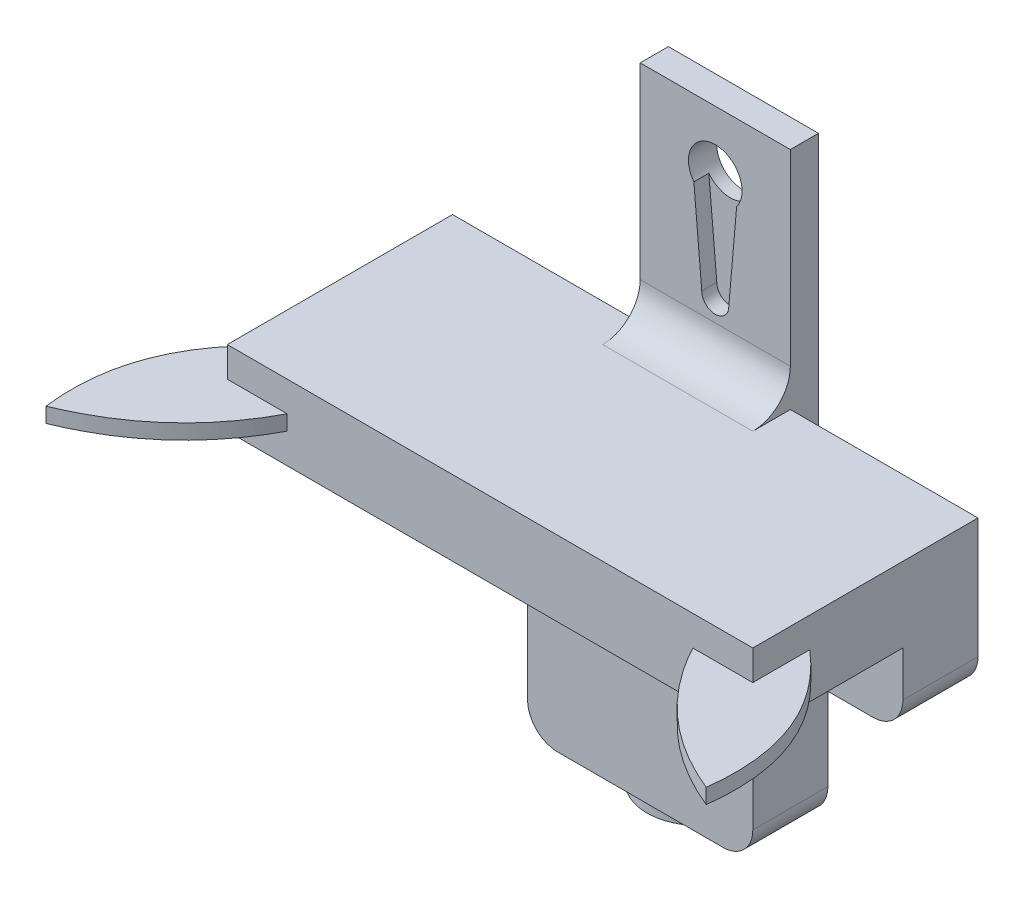
from build123d import *

# Parameters (mm, degrees)
SKETCH3_W            = 20
SKETCH3_H            = 50
BOSS_EXTRUDE3_DEPTH  = 5
CUT_EXTRUDE2_DEPTH   = 2
SKETCH6_R            = 3.57
CUT_EXTRUDE3_DEPTH   = 3
SKETCH8_W            = 1.25
SKETCH8_H            = 50
CUT_EXTRUDE5_DEPTH   = 30
SKETCH9_W            = 70
SKETCH9_H            = 20
BOSS_EXTRUDE4_DEPTH  = 20
SKETCH10_W           = 70
SKETCH10_H           = 10
CUT_EXTRUDE6_DEPTH   = 10
SKETCH11_W           = 30
SKETCH11_H           = 10
BOSS_EXTRUDE5_DEPTH  = 25
SKETCH12_W           = 20
SKETCH12_H           = 1.5
CUT_EXTRUDE7_DEPTH   = 1
SKETCH13_W           = 15
SKETCH13_H           = 38.806898948
CUT_EXTRUDE8_DEPTH   = 13
BOSS_EXTRUDE6_DEPTH  = 2
SKETCH16_R           = 0.75
CUT_EXTRUDE9_DEPTH   = 0.5
SKETCH19_W           = 70
SKETCH19_H           = 10
BOSS_EXTRUDE8_DEPTH  = 10
BOSS_EXTRUDE9_DEPTH  = 2
FILLET1_R            = 6
FILLET2_R            = 4
SKETCH22_W           = 15
SKETCH22_H           = 5
BOSS_EXTRUDE10_DEPTH = 25
FILLET3_R            = 5


with BuildPart() as part:
    # Sketch3 → Boss-Extrude3 (new body)
    with BuildSketch(Plane.XY):
        Rectangle(SKETCH3_W, SKETCH3_H)
    extrude(amount=BOSS_EXTRUDE3_DEPTH)

    # Sketch4 → Cut-Extrude2 (cut)
    with BuildSketch(Plane.XY.offset(5)):
        with BuildLine():
            Line((-2.85, 14.850023256), (-1.8, 2.795667197))
            Line((-1.8, 2.795667197), (1.8, 2.795667197))
            Line((1.8, 2.795667197), (2.85, 14.850023256))
            ThreePointArc((2.85, 14.850023256), (0, 13.43), (-2.85, 14.850023256))
        make_face()
        with BuildLine():
            Line((1.8, 2.795667197), (-1.8, 2.795667197))
            ThreePointArc((-1.8, 2.795667197), (0, 0.995667197), (1.8, 2.795667197))
        make_face()
        with BuildLine():
            ThreePointArc((3.57, 17), (-1.133666618, 20.385217866), (-2.85, 14.850023256))
            Line((-2.85, 14.850023256), (2.85, 14.850023256))
            ThreePointArc((2.85, 14.850023256), (3.385217866, 15.866333382), (3.57, 17))
        make_face()
        with BuildLine():
            Line((2.85, 14.850023256), (-2.85, 14.850023256))
            ThreePointArc((-2.85, 14.850023256), (0, 13.43), (2.85, 14.850023256))
        make_face()
    extrude(amount=-CUT_EXTRUDE2_DEPTH, mode=Mode.SUBTRACT)

    # Sketch6 → Cut-Extrude3 (cut)
    with BuildSketch(Plane.XY.offset(3)):
        with Locations((0, 17)):
            Circle(SKETCH6_R)
    extrude(amount=-CUT_EXTRUDE3_DEPTH, mode=Mode.SUBTRACT)

    # Sketch8 → Cut-Extrude5 (cut)
    with BuildSketch(Plane(origin=(10, 0, 0), x_dir=(0, 0, -1), z_dir=(1, 0, 0))):
        with Locations((-0.625, 0)):
            Rectangle(SKETCH8_W, SKETCH8_H)
    extrude(amount=-CUT_EXTRUDE5_DEPTH, mode=Mode.SUBTRACT)

    # Sketch9 → Boss-Extrude4 (add)
    with BuildSketch(Plane.XY.offset(5)):
        with Locations((0, -15)):
            Rectangle(SKETCH9_W, SKETCH9_H)
    extrude(amount=BOSS_EXTRUDE4_DEPTH)

    # Sketch10 → Cut-Extrude6 (cut)
    with BuildSketch(Plane.XY.offset(25)):
        with Locations((0, -20)):
            Rectangle(SKETCH10_W, SKETCH10_H)
    extrude(amount=-CUT_EXTRUDE6_DEPTH, mode=Mode.SUBTRACT)

    # Sketch11 → Boss-Extrude5 (add)
    with BuildSketch(Plane(origin=(0, -25, 0), x_dir=(-1, 0, 0), z_dir=(0, -1, 0))):
        with Locations((0, -10)):
            Rectangle(SKETCH11_W, SKETCH11_H)
    extrude(amount=BOSS_EXTRUDE5_DEPTH)

    # Sketch12 → Cut-Extrude7 (cut)
    with BuildSketch(Plane.XY.offset(15)):
        with Locations((0, -15.75)):
            Rectangle(SKETCH12_W, SKETCH12_H)
    extrude(amount=-CUT_EXTRUDE7_DEPTH, mode=Mode.SUBTRACT)

    # Sketch13 → Cut-Extrude8 (cut)
    with BuildSketch(Plane(origin=(0, -5, 0), x_dir=(1, 0, 0), z_dir=(0, 1, 0))):
        with Locations((0, 1.403449474)):
            Rectangle(SKETCH13_W, SKETCH13_H)
    extrude(amount=-CUT_EXTRUDE8_DEPTH, mode=Mode.SUBTRACT)

    # Sketch15 → Boss-Extrude6 (add)
    with BuildSketch(Plane.XZ.offset(50)):
        with BuildLine():
            Line((0, 7.1), (5.553473382, 11.361330003))
            ThreePointArc((5.553473382, 11.361330003), (0, 14.1), (-5.553473382, 11.361330003))
            Line((-5.553473382, 11.361330003), (0, 7.1))
        make_face()
    extrude(amount=BOSS_EXTRUDE6_DEPTH)

    # Sketch16 → Cut-Extrude9 (cut)
    with BuildSketch(Plane(origin=(0, -52, 0), x_dir=(-1, 0, 0), z_dir=(0, -1, 0))):
        with Locations((-1.5, -11.498525774)):
            Circle(SKETCH16_R)
        with Locations((1.5, -11.498525774)):
            Circle(SKETCH16_R)
    extrude(amount=-CUT_EXTRUDE9_DEPTH, mode=Mode.SUBTRACT)

    # Sketch19 → Boss-Extrude8 (add)
    with BuildSketch(Plane.XY.offset(25)):
        with Locations((0, -10)):
            Rectangle(SKETCH19_W, SKETCH19_H)
    extrude(amount=BOSS_EXTRUDE8_DEPTH)

    # Sketch21 → Boss-Extrude9 (add)
    with BuildSketch(Plane(origin=(0, -11, 0), x_dir=(-1, 0, 0), z_dir=(0, -1, 0))):
        with BuildLine():
            Line((-24.95459775, -30.351053915), (-33.467453748, -26.18260363))
            add(Edge.make_bspline(
                [(-33.467453748, -26.18260363), (-45.809189014, -35.587529887), (-43.975470741, -50.179256657)],
                knots=[0, 0, 0, 1, 1, 1], degree=2))
            add(Edge.make_bspline(
                [(-24.95459775, -30.351053915), (-30.210326616, -44.560066847), (-43.975470741, -50.179256657)],
                knots=[0, 0, 0, 1, 1, 1], degree=2))
        make_face()
        with BuildLine():
            Line((24.95459775, -30.351053915), (33.467453748, -26.18260363))
            add(Edge.make_bspline(
                [(33.467453748, -26.18260363), (45.809189014, -35.587529887), (43.975470741, -50.179256657)],
                knots=[0, 0, 0, 1, 1, 1], degree=2))
            add(Edge.make_bspline(
                [(24.95459775, -30.351053915), (30.210326616, -44.560066847), (43.975470741, -50.179256657)],
                knots=[0, 0, 0, 1, 1, 1], degree=2))
        make_face()
    extrude(amount=-BOSS_EXTRUDE9_DEPTH)

    # Fillet1
    fillet1_edges = [part.edges().sort_by_distance(p)[0] for p in [
        (-15, -25, 10),
        (15, -25, 10),
    ]]
    fillet(fillet1_edges, radius=FILLET1_R)

    # Fillet2
    fillet2_edges = [part.edges().sort_by_distance(p)[0] for p in [
        (35, -25, 10),
        (-35, -25, 10),
        (-15, -50, 10),
        (15, -50, 10),
    ]]
    fillet(fillet2_edges, radius=FILLET2_R)

    # Sketch22 → Boss-Extrude10 (add)
    with BuildSketch(Plane(origin=(0, 0, 1.25), x_dir=(-1, 0, 0), z_dir=(0, 0, -1))):
        with Locations((0, -7.5)):
            Rectangle(SKETCH22_W, SKETCH22_H)
    extrude(amount=-BOSS_EXTRUDE10_DEPTH)

    # Fillet3
    fillet3_edges = [part.edges().sort_by_distance(p)[0] for p in [
        (0, -5, 5),
    ]]
    fillet(fillet3_edges, radius=FILLET3_R)


solid = part.part
